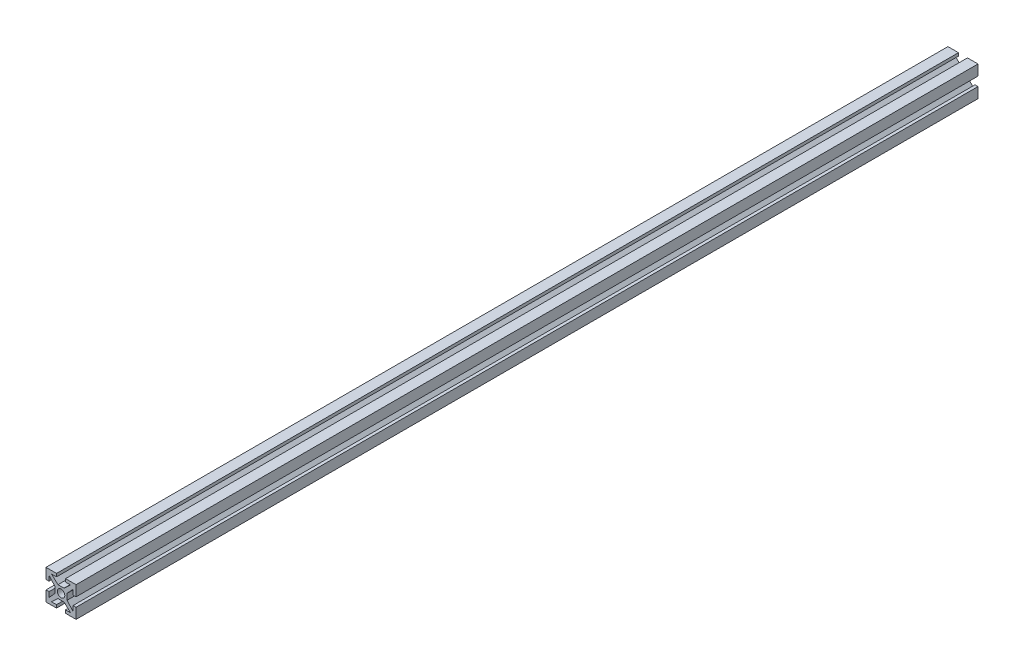
from build123d import *

# Parameters (mm, degrees)
SKETCH1_R           = 1.25
BOSS_EXTRUDE2_DEPTH = 300


with BuildPart() as part:
    # Sketch1 → Boss-Extrude2 (new body)
    with BuildSketch(Plane.XY):
        Polygon((-4, 3.181649314), (-2, 1), (-2, 0), (-2, -1), (-4, -3.181649314), (-4, -1.5), (-5, -1.5), (-5, -5), (-1.5, -5), (-1.5, -4), (-3.181649314, -4), (-1, -2), (0, -2), (1, -2), (3.181649314, -4), (1.5, -4), (1.5, -5), (5, -5), (5, -1.5), (4, -1.5), (4, -3.181649314), (2, -1), (2, 0), (2, 1), (4, 3.181649314), (4, 1.5), (5, 1.5), (5, 5), (1.5, 5), (1.5, 4), (3.181649314, 4), (1, 2), (0, 2), (-1, 2), (-3.181649314, 4), (-1.5, 4), (-1.5, 5), (-5, 5), (-5, 1.5), (-4, 1.5), align=None)
        Circle(SKETCH1_R, mode=Mode.SUBTRACT)
    extrude(amount=BOSS_EXTRUDE2_DEPTH)


solid = part.part
